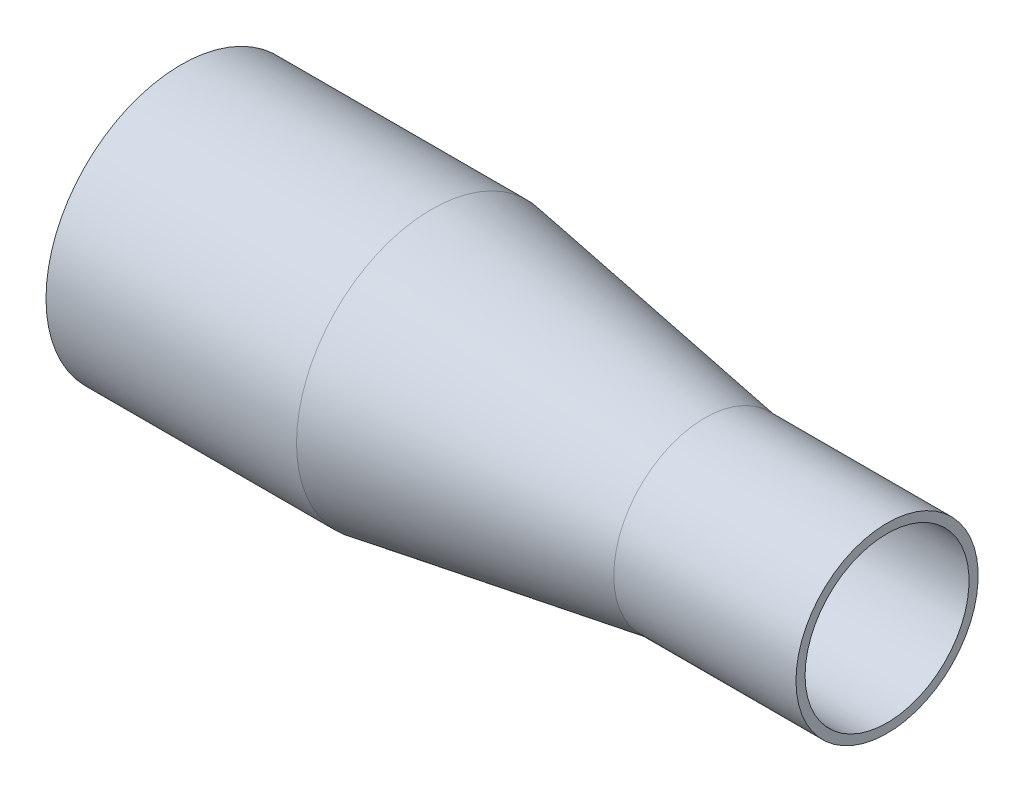
from build123d import *

# Parameters (mm, degrees)
SHELL1_T = -2.54


with BuildPart() as part:
    # Sketch1 → Revolve1 (revolve)
    with BuildSketch(Plane(origin=(0, 0, 0), x_dir=(1, 0, 0), z_dir=(0, 1, 0)), mode=Mode.PRIVATE) as revolve1_sk:
        Polygon((0, 0), (0, 37.6555), (69.85, 37.6555), (146.05, 25.4), (196.85, 25.4), (196.85, 0), align=None)
    revolve(revolve1_sk.sketch.rotate(Axis((0, 0, 0), (1, 0, 0)), 180), axis=Axis((0, 0, 0), (1, 0, 0)))

    # Shell1
    shell1_openings = [part.faces().sort_by_distance(p)[0] for p in [
        (196.85, 0, 0),
        (0, 0, 0),
    ]]
    offset(amount=SHELL1_T, openings=shell1_openings, kind=Kind.INTERSECTION)


solid = part.part
